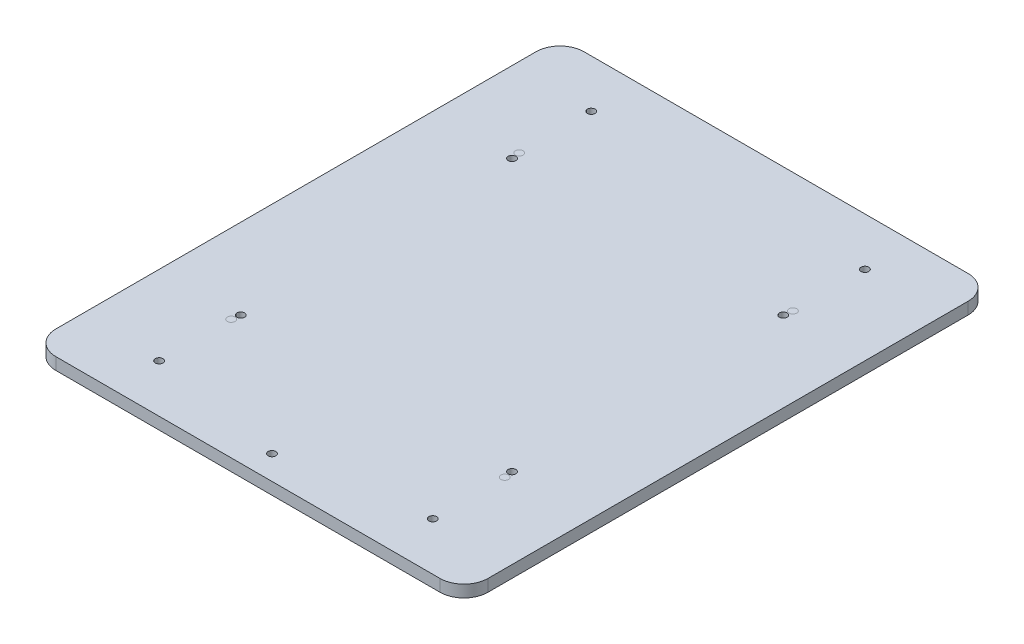
from build123d import *

# Parameters (mm, degrees)
SKETCH_1_R          = 1.6
EXTRUDE_1_DEPTH     = 5
SKETCH_4_R          = 1.6
CUT_EXTRUDE_2_DEPTH = 10
SKETCH_5_R          = 1.6
EXTRUDE_3_DEPTH     = 5
EXTRUDE_3_2_DEPTH   = 5
EXTRUDE_3_3_DEPTH   = 5
EXTRUDE_3_4_DEPTH   = 5
SKETCH_6_R          = 1.6
CUT_EXTRUDE_3_DEPTH = 5
SKETCH_8_R          = 1.6
CUT_EXTRUDE_4_DEPTH = 5


with BuildPart() as part:
    # 草图1 → 凸台-拉伸1 (new body)
    with BuildSketch(Plane(origin=(0, 0, 0), x_dir=(1, 0, 0), z_dir=(0, 1, 0))):
        with BuildLine():
            Line((-104.074074074, 85.341130604), (55.925925926, 85.341130604))
            ThreePointArc((55.925925926, 85.341130604), (62.996993738, 82.412198416), (65.925925926, 75.341130604))
            Line((65.925925926, 75.341130604), (65.925925926, -124.658869396))
            ThreePointArc((65.925925926, -124.658869396), (62.996993738, -131.729937208), (55.925925926, -134.658869396))
            Line((55.925925926, -134.658869396), (-104.074074074, -134.658869396))
            ThreePointArc((-104.074074074, -134.658869396), (-111.145141886, -131.729937208), (-114.074074074, -124.658869396))
            Line((-114.074074074, -124.658869396), (-114.074074074, 75.341130604))
            ThreePointArc((-114.074074074, 75.341130604), (-111.145141886, 82.412198416), (-104.074074074, 85.341130604))
        make_face()
        with Locations((-81.074074074, 35.341130604)):
            Circle(SKETCH_1_R, mode=Mode.SUBTRACT)
        with Locations((32.925925926, 35.341130604)):
            Circle(SKETCH_1_R, mode=Mode.SUBTRACT)
        with Locations((32.925925926, -84.658869396)):
            Circle(SKETCH_1_R, mode=Mode.SUBTRACT)
        with Locations((-81.074074074, -84.658869396)):
            Circle(SKETCH_1_R, mode=Mode.SUBTRACT)
    extrude(amount=EXTRUDE_1_DEPTH)

    # 草图4 → 切除-拉伸2 (cut)
    with BuildSketch(Plane(origin=(0, 5, 0), x_dir=(1, 0, 0), z_dir=(0, 1, 0))):
        with Locations((-81.074074074, 65.341130604)):
            Circle(SKETCH_4_R)
        with Locations((32.925925926, 65.341130604)):
            Circle(SKETCH_4_R)
        with Locations((-81.074074074, -114.658869396)):
            Circle(SKETCH_4_R)
        with Locations((32.925925926, -114.658869396)):
            Circle(SKETCH_4_R)
    extrude(amount=-CUT_EXTRUDE_2_DEPTH, mode=Mode.SUBTRACT)

    # 草图6 → 切除-拉伸3 (cut)
    with BuildSketch(Plane(origin=(0, 5, 0), x_dir=(1, 0, 0), z_dir=(0, 1, 0))):
        with Locations((-80.574074074, -81.158869396)):
            Circle(SKETCH_6_R)
        with Locations((-80.574074074, 31.841130604)):
            Circle(SKETCH_6_R)
        with Locations((32.425925926, 31.841130604)):
            Circle(SKETCH_6_R)
        with Locations((32.425925926, -81.158869396)):
            Circle(SKETCH_6_R)
    extrude(amount=-CUT_EXTRUDE_3_DEPTH, mode=Mode.SUBTRACT)

    # 草图8 → 切除-拉伸4 (cut)
    with BuildSketch(Plane.XZ):
        with Locations((-24.074074074, 124.658869396)):
            Circle(SKETCH_8_R)
    extrude(amount=-CUT_EXTRUDE_4_DEPTH, mode=Mode.SUBTRACT)


with BuildPart() as body_2:
    # 草图5 → 凸台-拉伸3 (new body)
    with BuildSketch(Plane(origin=(0, 5, 0), x_dir=(1, 0, 0), z_dir=(0, 1, 0))):
        with Locations((-81.074074074, 35.341130604)):
            Circle(SKETCH_5_R)
    extrude(amount=-EXTRUDE_3_DEPTH)


with BuildPart() as body_3:
    # 草图5 → Extrude 3 2 (new body)
    with BuildSketch(Plane(origin=(0, 5, 0), x_dir=(1, 0, 0), z_dir=(0, 1, 0))):
        with Locations((32.925925926, 35.341130604)):
            Circle(SKETCH_5_R)
    extrude(amount=-EXTRUDE_3_2_DEPTH)


with BuildPart() as body_4:
    # 草图5 → Extrude 3 3 (new body)
    with BuildSketch(Plane(origin=(0, 5, 0), x_dir=(1, 0, 0), z_dir=(0, 1, 0))):
        with Locations((32.925925926, -84.658869396)):
            Circle(SKETCH_5_R)
    extrude(amount=-EXTRUDE_3_3_DEPTH)


with BuildPart() as body_5:
    # 草图5 → Extrude 3 4 (new body)
    with BuildSketch(Plane(origin=(0, 5, 0), x_dir=(1, 0, 0), z_dir=(0, 1, 0))):
        with Locations((-81.074074074, -84.658869396)):
            Circle(SKETCH_5_R)
    extrude(amount=-EXTRUDE_3_4_DEPTH)


solid = Compound([part.part, body_2.part, body_3.part, body_4.part, body_5.part])
